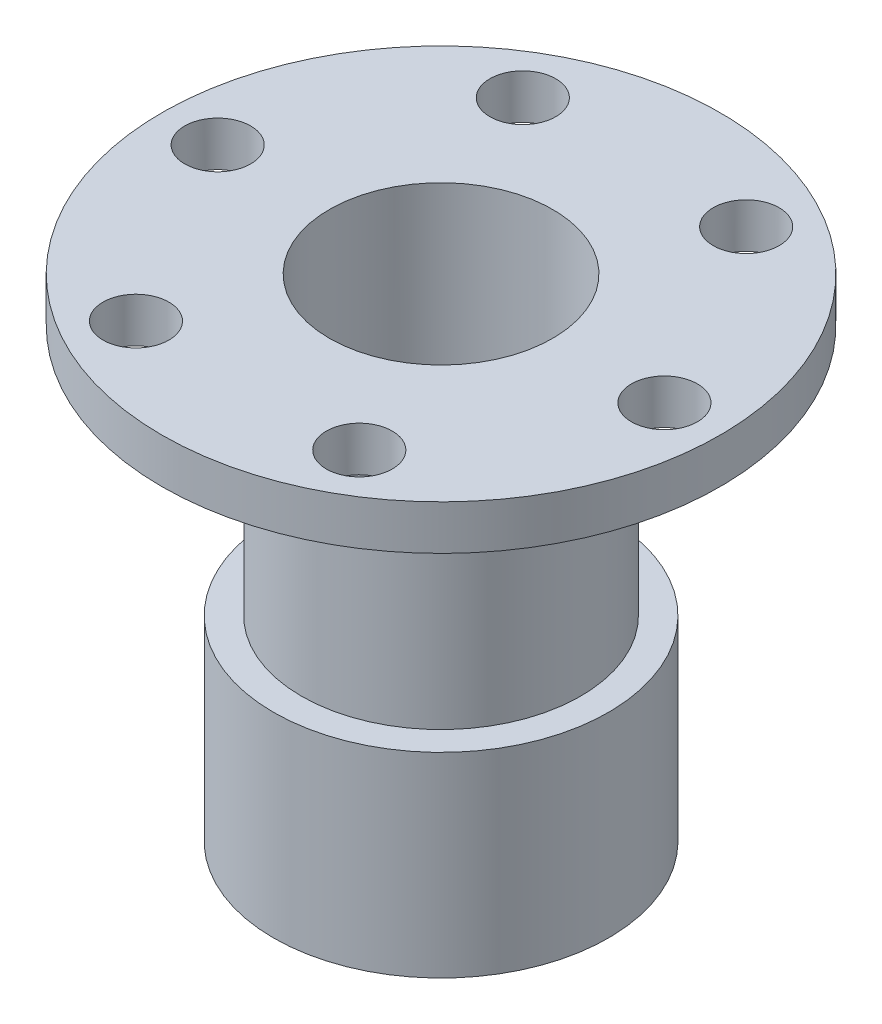
from build123d import *

# Parameters (mm, degrees)
SKETCH2_R           = 30
BOSS_EXTRUDE1_DEPTH = 35
SKETCH3_R           = 25
BOSS_EXTRUDE2_DEPTH = 45
SKETCH4_R           = 50
BOSS_EXTRUDE3_DEPTH = 8
SKETCH5_R           = 25
CUT_EXTRUDE1_DEPTH  = 25
CUT_EXTRUDE2_REACH  = 90
SKETCH6_R           = 20
SKETCH7_R           = 5.9
CUT_EXTRUDE3_DEPTH  = 40
CIRPATTERN1_COUNT   = 6


with BuildPart() as part:
    # Sketch2 → Boss-Extrude1 (new body)
    with BuildSketch(Plane(origin=(0, 0, 0), x_dir=(1, 0, 0), z_dir=(0, 1, 0))):
        Circle(SKETCH2_R)
    extrude(amount=BOSS_EXTRUDE1_DEPTH)

    # Sketch3 → Boss-Extrude2 (add)
    with BuildSketch(Plane(origin=(0, 35, 0), x_dir=(1, 0, 0), z_dir=(0, 1, 0))):
        Circle(SKETCH3_R)
    extrude(amount=BOSS_EXTRUDE2_DEPTH)

    # Sketch4 → Boss-Extrude3 (add)
    with BuildSketch(Plane(origin=(0, 80, 0), x_dir=(1, 0, 0), z_dir=(0, 1, 0))):
        Circle(SKETCH4_R)
    extrude(amount=BOSS_EXTRUDE3_DEPTH)

    # Sketch5 → Cut-Extrude1 (cut)
    with BuildSketch(Plane.XZ):
        Circle(SKETCH5_R)
    extrude(amount=-CUT_EXTRUDE1_DEPTH, mode=Mode.SUBTRACT)

    # Sketch6 → Cut-Extrude2 (cut, up to next)
    with BuildSketch(Plane(origin=(0, 88, 0), x_dir=(1, 0, 0), z_dir=(0, 1, 0)), mode=Mode.PRIVATE) as cut_extrude2_sk1:
        Circle(SKETCH6_R)
    cut_extrude2_tool1 = extrude(cut_extrude2_sk1.sketch, amount=-CUT_EXTRUDE2_REACH, mode=Mode.PRIVATE) & part.part
    add(cut_extrude2_tool1.solids().sort_by_distance((0, 88, 0))[0], mode=Mode.SUBTRACT)

    # Sketch7 → Cut-Extrude3 (cut)
    with BuildSketch(Plane(origin=(0, 88, 0), x_dir=(1, 0, 0), z_dir=(0, 1, 0))):
        with Locations((40, 0)):
            Circle(SKETCH7_R)
    cut_extrude3 = extrude(amount=-CUT_EXTRUDE3_DEPTH, mode=Mode.SUBTRACT)

    # CirPattern1: Cut-Extrude3 ×6 about axis
    cirpattern1_axis = Axis((0, 0, 0), (0, 1, 0))
    for i in range(1, CIRPATTERN1_COUNT):
        add(cut_extrude3.rotate(cirpattern1_axis, i * 360 / CIRPATTERN1_COUNT), mode=Mode.SUBTRACT)


solid = part.part
